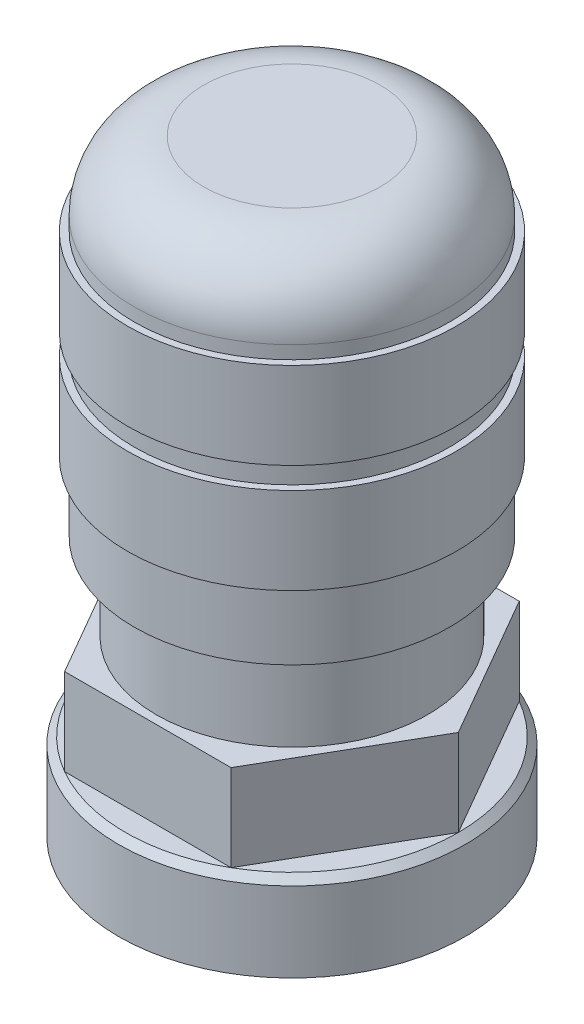
from build123d import *

# Parameters (mm, degrees)
SKETCH1_R      = 6.35
EXTRUDE1_DEPTH = 3.175
CHAMFER1_SIZE  = 0.254
EXTRUDE2_DEPTH = 3.175
SKETCH5_R      = 3.96875
EXTRUDE4_DEPTH = 12.7


with BuildPart() as part:
    # Sketch1 → Extrude1 (new body)
    with BuildSketch(Plane(origin=(0, 0, 0), x_dir=(1, 0, 0), z_dir=(0, 1, 0))):
        Circle(SKETCH1_R)
    extrude(amount=-EXTRUDE1_DEPTH)

    # Chamfer1
    chamfer1_edges = [part.edges().sort_by_distance(p)[0] for p in [
        (-6.35, 0, 0),
    ]]
    chamfer(chamfer1_edges, length=CHAMFER1_SIZE)

    # Sketch2 → Extrude2 (add)
    with BuildSketch(Plane(origin=(0, 0, 0), x_dir=(-1, 0, 0), z_dir=(0, 1, 0))):
        Polygon((-6.096, 0), (-3.048, -5.279290861), (3.048, -5.279290861), (6.096, 0), (3.048, 5.279290861), (-3.048, 5.279290861), align=None)
    extrude(amount=EXTRUDE2_DEPTH)

    # Sketch4 → Revolve1 (revolve)
    with BuildSketch(Plane(origin=(0, 0, 0), x_dir=(0, 0, -1), z_dir=(1, 0, 0))):
        with BuildLine():
            Line((-4.97229944, 3.175), (-4.97229944, 6.35))
            Line((-4.97229944, 6.35), (-5.772606153, 6.35))
            Line((-5.772606153, 6.35), (-5.772606153, 8.887450179))
            Line((-5.772606153, 8.887450179), (-6.026606153, 8.887450179))
            Line((-6.026606153, 8.887450179), (-6.026606153, 12.062450179))
            Line((-6.026606153, 12.062450179), (-5.772606153, 12.062450179))
            Line((-5.772606153, 12.062450179), (-5.772606153, 12.856200179))
            Line((-5.772606153, 12.856200179), (-6.026606153, 12.856200179))
            Line((-6.026606153, 12.856200179), (-6.026606153, 16.031200179))
            Line((-6.026606153, 16.031200179), (-5.772606153, 16.031200179))
            Line((-5.772606153, 16.031200179), (-5.772606153, 16.51))
            ThreePointArc((-5.772606153, 16.51), (-5.028657378, 18.306051224), (-3.232606153, 19.05))
            Line((-3.232606153, 19.05), (0, 19.05))
            Line((0, 19.05), (0, 17.78))
            Line((0, 17.78), (-3.232606153, 17.78))
            ThreePointArc((-3.232606153, 17.78), (-4.130631766, 17.408025612), (-4.502606153, 16.51))
            Line((-4.502606153, 16.51), (-4.502606153, 14.761200179))
            Line((-4.502606153, 14.761200179), (-4.756606153, 14.761200179))
            Line((-4.756606153, 14.761200179), (-4.756606153, 14.126200179))
            Line((-4.756606153, 14.126200179), (-4.502606153, 14.126200179))
            Line((-4.502606153, 14.126200179), (-4.502606153, 10.792450179))
            Line((-4.502606153, 10.792450179), (-4.756606153, 10.792450179))
            Line((-4.756606153, 10.792450179), (-4.756606153, 10.157450179))
            Line((-4.756606153, 10.157450179), (-4.502606153, 10.157450179))
            Line((-4.502606153, 10.157450179), (-4.502606153, 7.62))
            Line((-4.502606153, 7.62), (-3.70229944, 7.62))
            Line((-3.70229944, 7.62), (-3.70229944, 4.445))
            Line((-3.70229944, 4.445), (0, 4.445))
            Line((0, 4.445), (0, 3.175))
            Line((0, 3.175), (-4.97229944, 3.175))
        make_face()
    revolve(axis=Axis((0, 20.169611013, 0), (0, -1, 0)))

    # Sketch5 → Extrude4 (cut)
    with BuildSketch(Plane.XZ.offset(3.175)):
        Circle(SKETCH5_R)
    extrude(amount=-EXTRUDE4_DEPTH, mode=Mode.SUBTRACT)


solid = part.part
